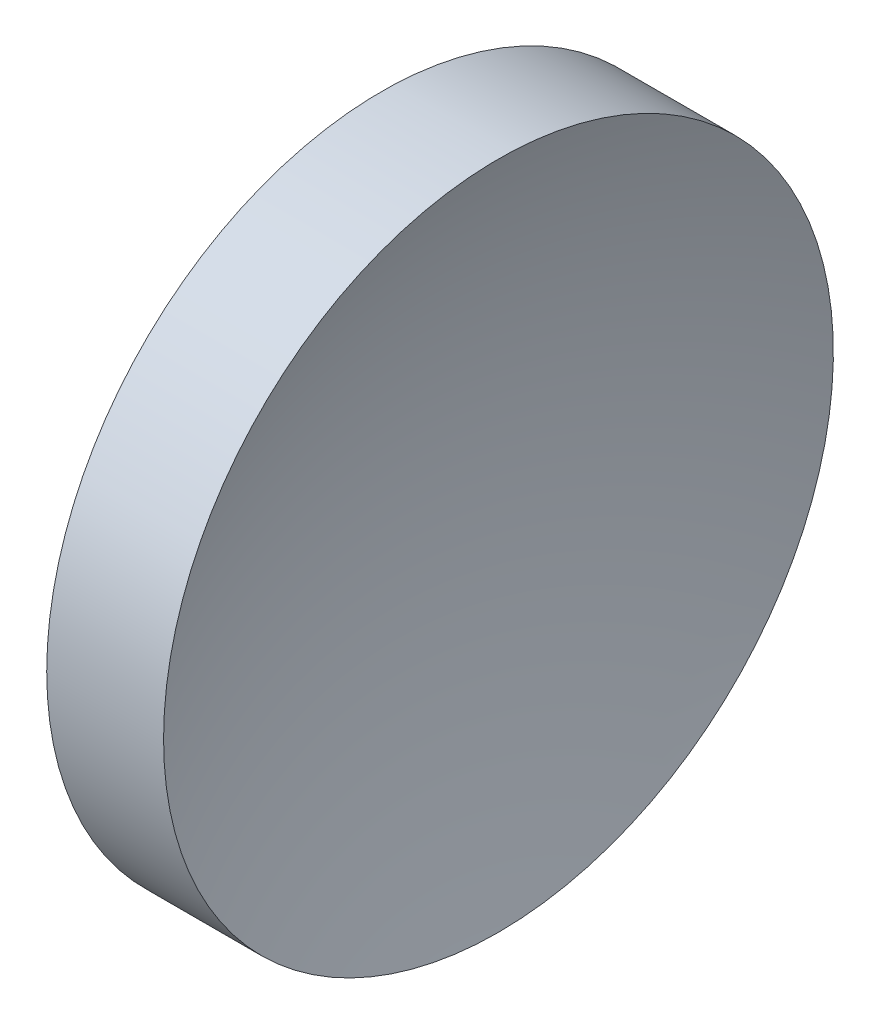
from build123d import *


with BuildPart() as part:
    # 草图1 → 旋转1 (revolve)
    with BuildSketch(Plane.XY, mode=Mode.PRIVATE) as revolve_1_sk:
        with BuildLine():
            Line((119.362930792, 71.193989087), (119.362930792, 83.893989087))
            Line((119.362930792, 83.893989087), (123.793861657, 83.893989087))
            ThreePointArc((123.793861657, 83.893989087), (121.976130414, 77.659269917), (121.362930792, 71.193989087))
            Line((121.362930792, 71.193989087), (119.362930792, 71.193989087))
        make_face()
    revolve(revolve_1_sk.sketch.rotate(Axis((111.955229758, 71.193989087, 0), (1, 0, 0)), 180), axis=Axis((111.955229758, 71.193989087, 0), (1, 0, 0)))  # turned: the seam where the file's is


solid = part.part
